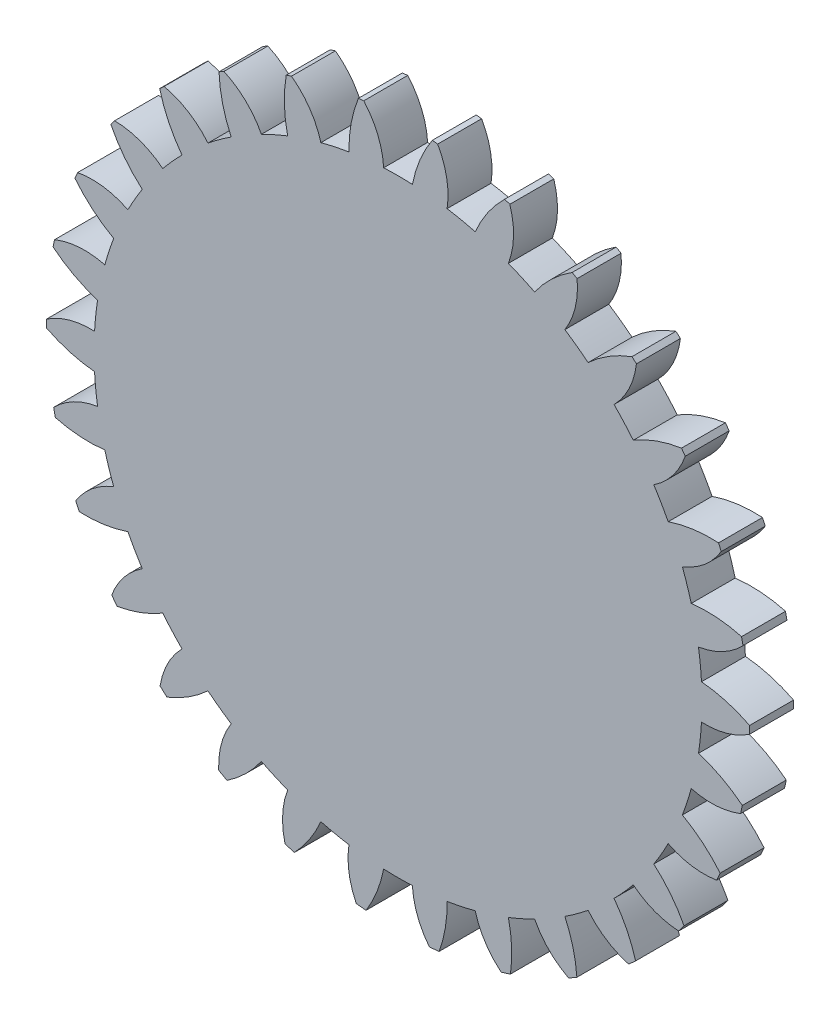
from build123d import *

# Parameters (mm, degrees)
SKETCH2_R           = 609.6
BOSS_EXTRUDE2_DEPTH = 76.2
CUT_EXTRUDE1_DEPTH  = 77.2
CIRPATTERN1_COUNT   = 30


with BuildPart() as part:
    # Sketch2 → Boss-Extrude2 (new body)
    with BuildSketch(Plane.XY):
        Circle(SKETCH2_R)
    extrude(amount=BOSS_EXTRUDE2_DEPTH)

    # Sketch3 → Cut-Extrude1 (cut, through all)
    with BuildSketch(Plane.XY.offset(76.2)):
        with BuildLine():
            ThreePointArc((24.912616177, 523.282311167), (0, 523.875), (-24.912616177, 523.282311167))
            ThreePointArc((-24.912616177, 523.282311167), (-35.087110683, 567.908462249), (-59.380088455, 606.701050844))
            ThreePointArc((-59.380088455, 606.701050844), (0, 609.6), (59.380088455, 606.701050844))
            ThreePointArc((59.380088455, 606.701050844), (37.988368572, 566.709702519), (24.912616177, 523.282311167))
        make_face()
    cut_extrude1 = extrude(amount=-CUT_EXTRUDE1_DEPTH, mode=Mode.SUBTRACT)

    # CirPattern1: Cut-Extrude1 ×30 about axis
    cirpattern1_axis = Axis((-0.006195071, -3.21023047, 0), (0, 0, 1))
    for i in range(1, CIRPATTERN1_COUNT):
        add(cut_extrude1.rotate(cirpattern1_axis, i * 360 / CIRPATTERN1_COUNT), mode=Mode.SUBTRACT)


solid = part.part
